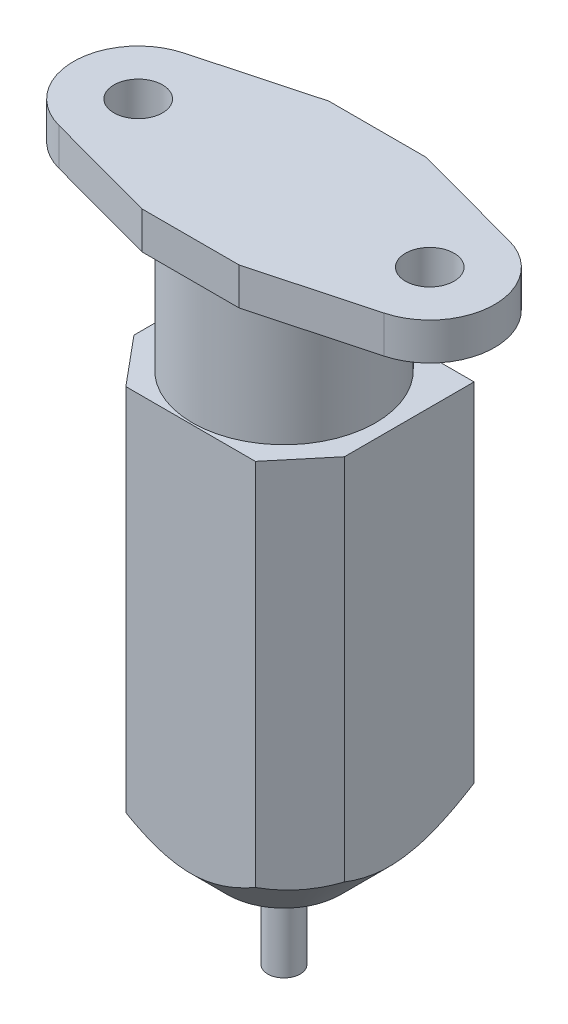
from build123d import *

# Parameters (mm, degrees)
SKETCH1_R           = 1.5
BOSS_EXTRUDE1_DEPTH = 2.3
SKETCH2_R           = 5.65
BOSS_EXTRUDE2_DEPTH = 7.7
BOSS_EXTRUDE3_DEPTH = 26.3
SKETCH5_R           = 1
BOSS_EXTRUDE4_DEPTH = 5.5


with BuildPart() as part:
    # Sketch1 → Boss-Extrude1 (new body)
    with BuildSketch(Plane(origin=(0, 0, 0), x_dir=(1, 0, 0), z_dir=(0, 1, 0))):
        with BuildLine():
            Line((-3, 5.765), (3, 5.765))
            Line((3, 5.765), (10.043565082, 3.861472766))
            ThreePointArc((10.043565082, 3.861472766), (13, 0), (10.043565082, -3.861472766))
            Line((10.043565082, -3.861472766), (3, -5.765))
            Line((3, -5.765), (-3, -5.765))
            Line((-3, -5.765), (-10.043565082, -3.861472766))
            ThreePointArc((-10.043565082, -3.861472766), (-13, 0), (-10.043565082, 3.861472766))
            Line((-10.043565082, 3.861472766), (-3, 5.765))
        make_face()
        with Locations((9, 0)):
            Circle(SKETCH1_R, mode=Mode.SUBTRACT)
        with Locations((-9, 0)):
            Circle(SKETCH1_R, mode=Mode.SUBTRACT)
    extrude(amount=-BOSS_EXTRUDE1_DEPTH)

    # Sketch2 → Boss-Extrude2 (add)
    with BuildSketch(Plane.XZ.offset(2.3)):
        Circle(SKETCH2_R)
    extrude(amount=BOSS_EXTRUDE2_DEPTH)

    # Sketch3 → Boss-Extrude3 (add)
    with BuildSketch(Plane.XZ.offset(10)):
        Polygon((-4, 5.765), (4, 5.765), (6.5, 2.765), (6.5, -5.235), (-6.5, -5.235), (-6.5, 2.765), align=None)
    extrude(amount=BOSS_EXTRUDE3_DEPTH)

    # Sketch4 → Cut-Revolve1 (revolve, cut)
    with BuildSketch(Plane.XY):
        Polygon((3.5, -36.3), (10, -29.8), (10, -36.3), align=None)
    revolve(axis=Axis((0, -36.3, 0), (0, 1, 0)), mode=Mode.SUBTRACT)

    # Sketch5 → Boss-Extrude4 (add)
    with BuildSketch(Plane.XZ.offset(36.3)):
        Circle(SKETCH5_R)
    extrude(amount=BOSS_EXTRUDE4_DEPTH)


solid = part.part
